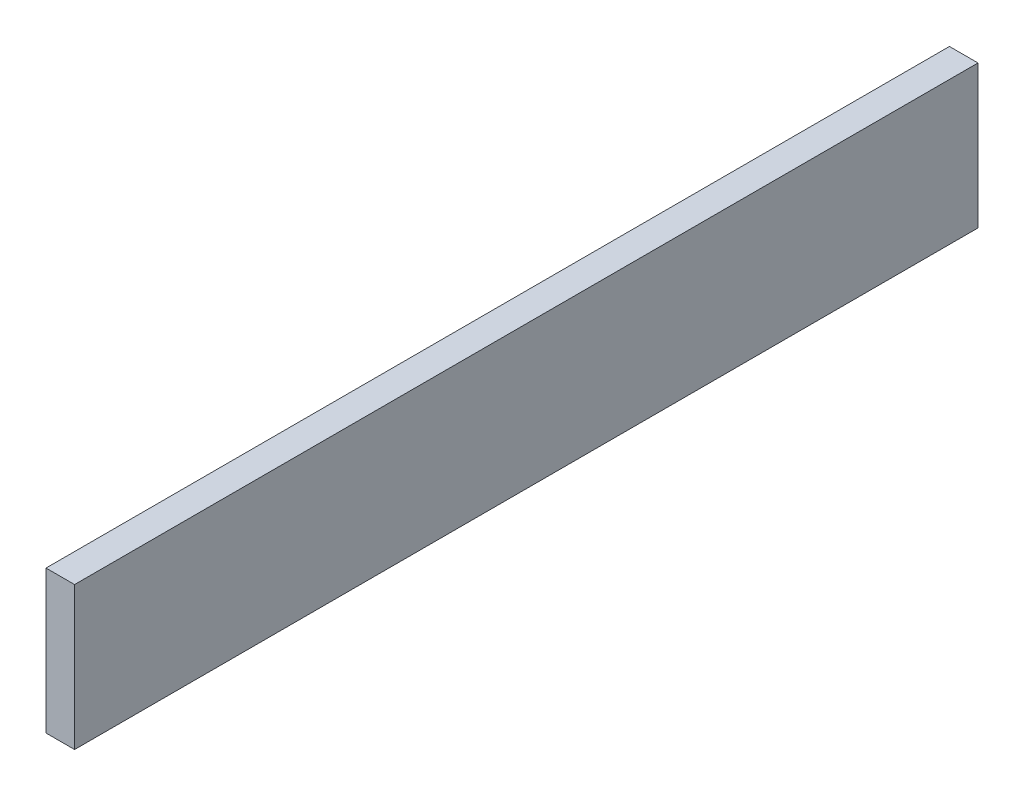
from build123d import *

# Parameters (mm, degrees)
SKETCH_1_W      = 31.61
SKETCH_1_H      = 5
EXTRUDE_1_DEPTH = 1


with BuildPart() as part:
    # Эскиз1 → Бобышка-Вытянуть1 (new body)
    with BuildSketch(Plane(origin=(0, 0, 0), x_dir=(0, 0, -1), z_dir=(1, 0, 0))):
        with Locations((15.805, 2.5)):
            Rectangle(SKETCH_1_W, SKETCH_1_H)
    extrude(amount=EXTRUDE_1_DEPTH)


solid = part.part
